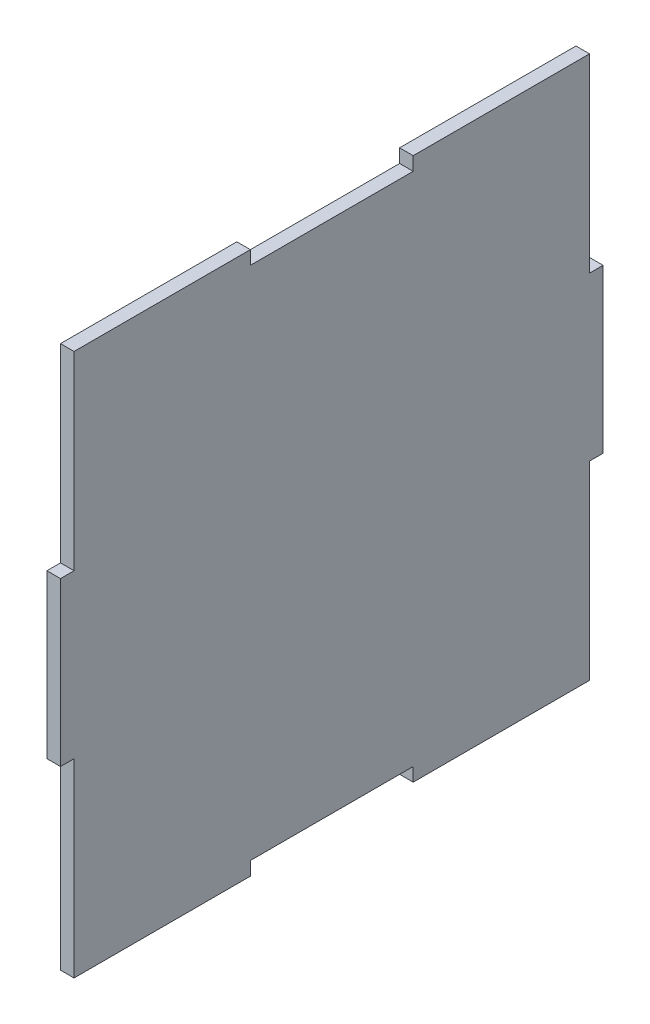
from build123d import *

# Parameters (mm, degrees)
BOSS_EXTRUDE1_DEPTH = 3.175


with BuildPart() as part:
    # Sketch1 → Boss-Extrude1 (new body)
    with BuildSketch(Plane(origin=(0, 0, 0), x_dir=(0, 0, -1), z_dir=(1, 0, 0))):
        Polygon((19.05, 63.5), (60.325, 63.5), (60.325, 19.05), (63.5, 19.05), (63.5, -19.05), (60.325, -19.05), (60.325, -63.5), (19.05, -63.5), (19.05, -60.325), (-19.05, -60.325), (-19.05, -63.5), (-60.325, -63.5), (-60.325, -19.05), (-63.5, -19.05), (-63.5, 19.05), (-60.325, 19.05), (-60.325, 63.5), (-19.05, 63.5), (-19.05, 60.325), (19.05, 60.325), align=None)
    extrude(amount=BOSS_EXTRUDE1_DEPTH)


solid = part.part
